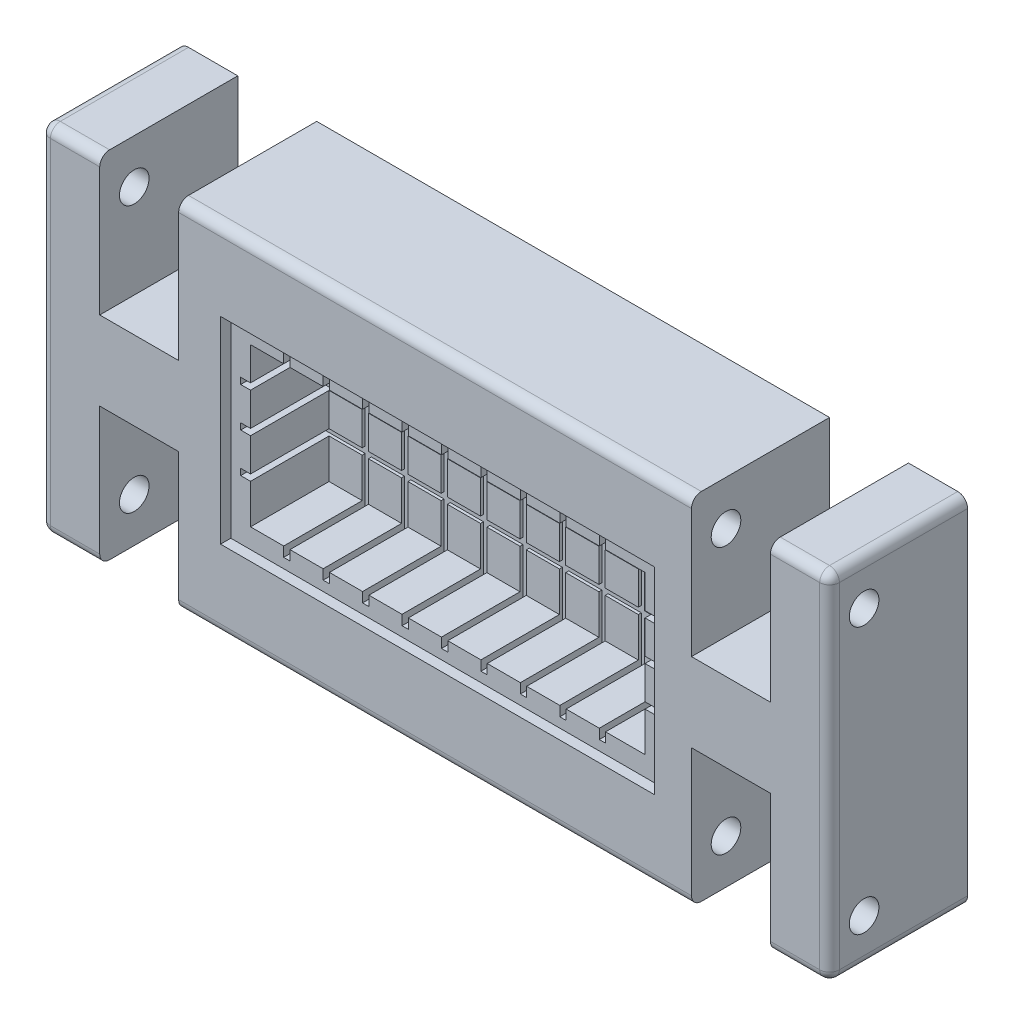
from build123d import *

# Parameters (mm, degrees)
CROQUIS2_W              = 400
CROQUIS2_H              = 180
SALIENTE_EXTRUIR3_DEPTH = 70
CROQUIS3_W              = 40
CROQUIS3_H              = 70
CORTAR_EXTRUIR1_DEPTH   = 70
CROQUIS4_R              = 7.5
CORTAR_EXTRUIR2_DEPTH   = 400
REDONDEO2_R             = 5
REDONDEO3_R             = 5
REDONDEO4_R             = 5
REDONDEO5_R             = 5
REDONDEO6_R             = 5
REDONDEO7_R             = 5
REDONDEO8_R             = 5
REDONDEO9_R             = 5
CROQUIS6_W              = 200
CROQUIS6_H              = 80
CORTAR_EXTRUIR3_DEPTH   = 45
CROQUIS7_W              = 3.2
CROQUIS7_H              = 90
CORTAR_EXTRUIR4_DEPTH   = 46.5
CROQUIS8_W              = 210
CROQUIS8_H              = 3.2
CORTAR_EXTRUIR5_DEPTH   = 46.5
CROQUIS9_W              = 220
CROQUIS9_H              = 100
CORTAR_EXTRUIR6_DEPTH   = 5.2


with BuildPart() as part:
    # Croquis2 → Saliente-Extruir3 (new body)
    with BuildSketch(Plane.XY):
        with Locations((200, 90)):
            Rectangle(CROQUIS2_W, CROQUIS2_H)
    extrude(amount=SALIENTE_EXTRUIR3_DEPTH)

    # Croquis3 → Cortar-Extruir1 (cut)
    with BuildSketch(Plane.XY.offset(70)):
        with Locations((50, 145)):
            Rectangle(CROQUIS3_W, CROQUIS3_H)
        with Locations((350, 35)):
            Rectangle(CROQUIS3_W, CROQUIS3_H)
        with Locations((50, 35)):
            Rectangle(CROQUIS3_W, CROQUIS3_H)
        with Locations((350, 145)):
            Rectangle(CROQUIS3_W, CROQUIS3_H)
    extrude(amount=-CORTAR_EXTRUIR1_DEPTH, mode=Mode.SUBTRACT)

    # Croquis4 → Cortar-Extruir2 (cut)
    with BuildSketch(Plane(origin=(400, 0, 0), x_dir=(0, 0, -1), z_dir=(1, 0, 0))):
        with Locations((-52.5, 157.5)):
            Circle(CROQUIS4_R)
        with Locations((-52.5, 22.5)):
            Circle(CROQUIS4_R)
    extrude(amount=-CORTAR_EXTRUIR2_DEPTH, mode=Mode.SUBTRACT)

    # Redondeo2
    redondeo2_edges = [part.edges().sort_by_distance(p)[0] for p in [
        (200, 0, 70),
    ]]
    fillet(redondeo2_edges, radius=REDONDEO2_R)

    # Redondeo3
    redondeo3_edges = [part.edges().sort_by_distance(p)[0] for p in [
        (200, 180, 70),
    ]]
    fillet(redondeo3_edges, radius=REDONDEO3_R)

    # Redondeo4
    redondeo4_edges = [part.edges().sort_by_distance(p)[0] for p in [
        (15, 180, 70),
    ]]
    fillet(redondeo4_edges, radius=REDONDEO4_R)

    # Redondeo5
    redondeo5_edges = [part.edges().sort_by_distance(p)[0] for p in [
        (385, 180, 70),
    ]]
    fillet(redondeo5_edges, radius=REDONDEO5_R)

    # Redondeo6
    redondeo6_edges = [part.edges().sort_by_distance(p)[0] for p in [
        (385, 0, 70),
    ]]
    fillet(redondeo6_edges, radius=REDONDEO6_R)

    # Redondeo7
    redondeo7_edges = [part.edges().sort_by_distance(p)[0] for p in [
        (15, 0, 70),
    ]]
    fillet(redondeo7_edges, radius=REDONDEO7_R)

    # Redondeo8
    redondeo8_edges = [part.edges().sort_by_distance(p)[0] for p in [
        (0, 90, 70),
        (0, 180, 32.5),
        (0, 0, 32.5),
    ]]
    fillet(redondeo8_edges, radius=REDONDEO8_R)

    # Redondeo9
    redondeo9_edges = [part.edges().sort_by_distance(p)[0] for p in [
        (400, 180, 32.5),
        (400, 90, 70),
        (400, 0, 32.5),
    ]]
    fillet(redondeo9_edges, radius=REDONDEO9_R)

    # Croquis6 → Cortar-Extruir3 (cut)
    with BuildSketch(Plane.XY.offset(70)):
        with Locations((201.25, 90)):
            Rectangle(CROQUIS6_W, CROQUIS6_H)
    extrude(amount=-CORTAR_EXTRUIR3_DEPTH, mode=Mode.SUBTRACT)

    # Croquis7 → Cortar-Extruir4 (cut)
    with BuildSketch(Plane.XY.offset(70)):
        with Locations((239.65, 90)):
            Rectangle(CROQUIS7_W, CROQUIS7_H)
        with Locations((139.65, 90)):
            Rectangle(CROQUIS7_W, CROQUIS7_H)
        with Locations((119.65, 90)):
            Rectangle(CROQUIS7_W, CROQUIS7_H)
        with Locations((159.65, 90)):
            Rectangle(CROQUIS7_W, CROQUIS7_H)
        with Locations((179.65, 90)):
            Rectangle(CROQUIS7_W, CROQUIS7_H)
        with Locations((199.65, 90)):
            Rectangle(CROQUIS7_W, CROQUIS7_H)
        with Locations((219.65, 90)):
            Rectangle(CROQUIS7_W, CROQUIS7_H)
        with Locations((259.65, 90)):
            Rectangle(CROQUIS7_W, CROQUIS7_H)
        with Locations((279.65, 90)):
            Rectangle(CROQUIS7_W, CROQUIS7_H)
    extrude(amount=-CORTAR_EXTRUIR4_DEPTH, mode=Mode.SUBTRACT)

    # Croquis8 → Cortar-Extruir5 (cut)
    with BuildSketch(Plane.XY.offset(70)):
        with Locations((201.25, 111.6)):
            Rectangle(CROQUIS8_W, CROQUIS8_H)
        with Locations((201.25, 91.6)):
            Rectangle(CROQUIS8_W, CROQUIS8_H)
        with Locations((201.25, 71.6)):
            Rectangle(CROQUIS8_W, CROQUIS8_H)
    extrude(amount=-CORTAR_EXTRUIR5_DEPTH, mode=Mode.SUBTRACT)

    # Croquis9 → Cortar-Extruir6 (cut)
    with BuildSketch(Plane.XY.offset(70)):
        with Locations((201.25, 90)):
            Rectangle(CROQUIS9_W, CROQUIS9_H)
    extrude(amount=-CORTAR_EXTRUIR6_DEPTH, mode=Mode.SUBTRACT)


solid = part.part
